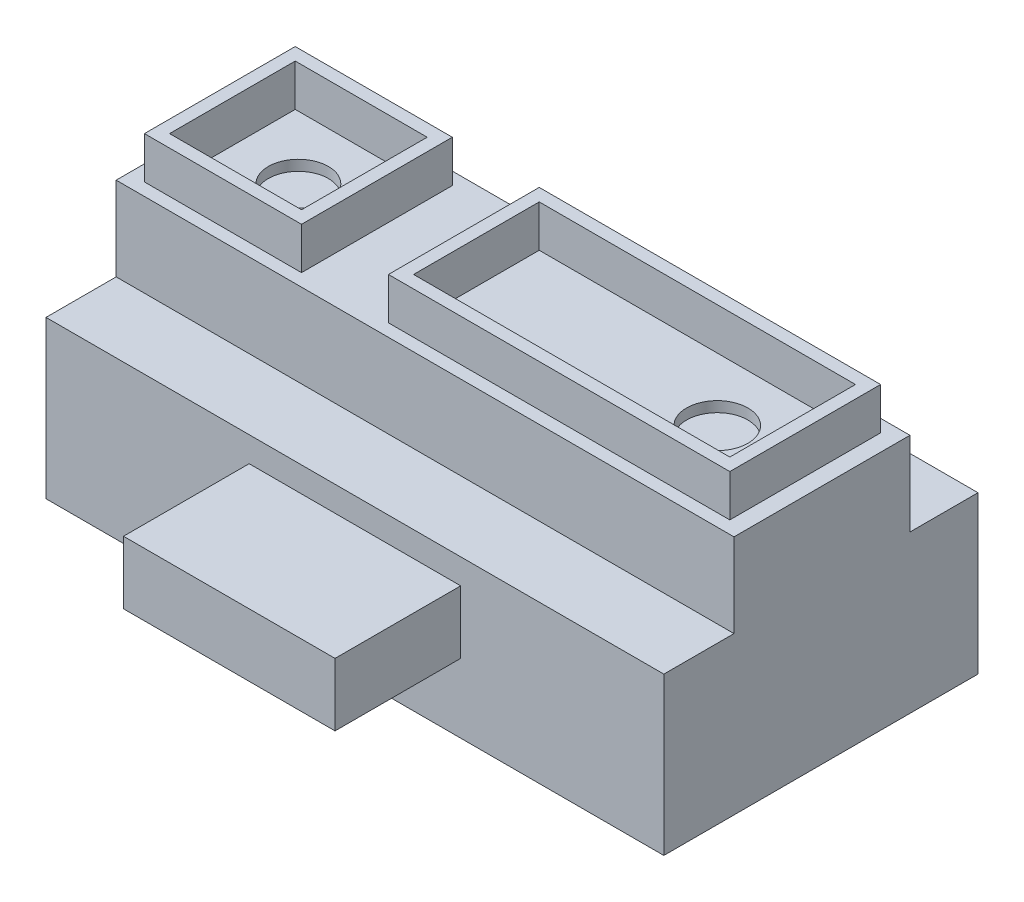
from build123d import *

# Parameters (mm, degrees)
SKIZZE2_W                       = 29.5
SKIZZE2_H                       = 15
AUFSATZ_LINEAR_AUSTRAGEN1_DEPTH = 7.5
SKIZZE4_W                       = 27.9
SKIZZE4_H                       = 13.4
SCHNITT_LINEAR_AUSTRAGEN1_DEPTH = 5.7
SKIZZE5_W                       = 29.5
SKIZZE5_H                       = 8.4
AUFSATZ_LINEAR_AUSTRAGEN2_DEPTH = 4
SKIZZE7_W                       = 7.5
SKIZZE7_H                       = 7.2
SKIZZE7_W_2                     = 6.3
SKIZZE7_H_2                     = 6
SKIZZE7_W_3                     = 16.3
SKIZZE7_W_4                     = 15.1
AUFSATZ_LINEAR_AUSTRAGEN3_DEPTH = 2
SKIZZE8_R                       = 1.434086585
SKIZZE8_R_2                     = 1.463442441
SCHNITT_LINEAR_AUSTRAGEN2_DEPTH = 0.5
SKIZZE9_W                       = 10.1
SKIZZE9_H                       = 3
AUFSATZ_LINEAR_AUSTRAGEN4_DEPTH = 6


with BuildPart() as part:
    # Skizze2 → Aufsatz-Linear austragen1 (new body)
    with BuildSketch(Plane(origin=(0, 0, 0), x_dir=(1, 0, 0), z_dir=(0, 1, 0))):
        with Locations((14.75, 7.5)):
            Rectangle(SKIZZE2_W, SKIZZE2_H)
    extrude(amount=AUFSATZ_LINEAR_AUSTRAGEN1_DEPTH)

    # Skizze4 → Schnitt-Linear austragen1 (cut)
    with BuildSketch(Plane.XZ):
        with Locations((14.75, -7.5)):
            Rectangle(SKIZZE4_W, SKIZZE4_H)
    extrude(amount=-SCHNITT_LINEAR_AUSTRAGEN1_DEPTH, mode=Mode.SUBTRACT)

    # Skizze5 → Aufsatz-Linear austragen2 (add)
    with BuildSketch(Plane(origin=(0, 7.5, 0), x_dir=(1, 0, 0), z_dir=(0, 1, 0))):
        with Locations((14.75, 7.55)):
            Rectangle(SKIZZE5_W, SKIZZE5_H)
    extrude(amount=AUFSATZ_LINEAR_AUSTRAGEN2_DEPTH)

    # Skizze7 → Aufsatz-Linear austragen3 (add)
    with BuildSketch(Plane(origin=(0, 11.5, 0), x_dir=(1, 0, 0), z_dir=(0, 1, 0))):
        with Locations((4.5, 7.55)):
            Rectangle(SKIZZE7_W, SKIZZE7_H)
        with Locations((4.5, 7.55)):
            Rectangle(SKIZZE7_W_2, SKIZZE7_H_2, mode=Mode.SUBTRACT)
        with Locations((20.55, 7.55)):
            Rectangle(SKIZZE7_W_3, SKIZZE7_H)
        with Locations((20.55, 7.55)):
            Rectangle(SKIZZE7_W_4, SKIZZE7_H_2, mode=Mode.SUBTRACT)
    extrude(amount=AUFSATZ_LINEAR_AUSTRAGEN3_DEPTH)

    # Skizze8 → Schnitt-Linear austragen2 (cut)
    with BuildSketch(Plane(origin=(0, 11.5, 0), x_dir=(-1, 0, 0), z_dir=(0, 1, 0))):
        with Locations((-4.5, -7.55)):
            Circle(SKIZZE8_R)
        with Locations((-24.5, -7.55)):
            Circle(SKIZZE8_R_2)
    extrude(amount=-SCHNITT_LINEAR_AUSTRAGEN2_DEPTH, mode=Mode.SUBTRACT)

    # Skizze9 → Aufsatz-Linear austragen4 (add)
    with BuildSketch(Plane.XY):
        with Locations((14.75, 4.8)):
            Rectangle(SKIZZE9_W, SKIZZE9_H)
    extrude(amount=AUFSATZ_LINEAR_AUSTRAGEN4_DEPTH)


solid = part.part
